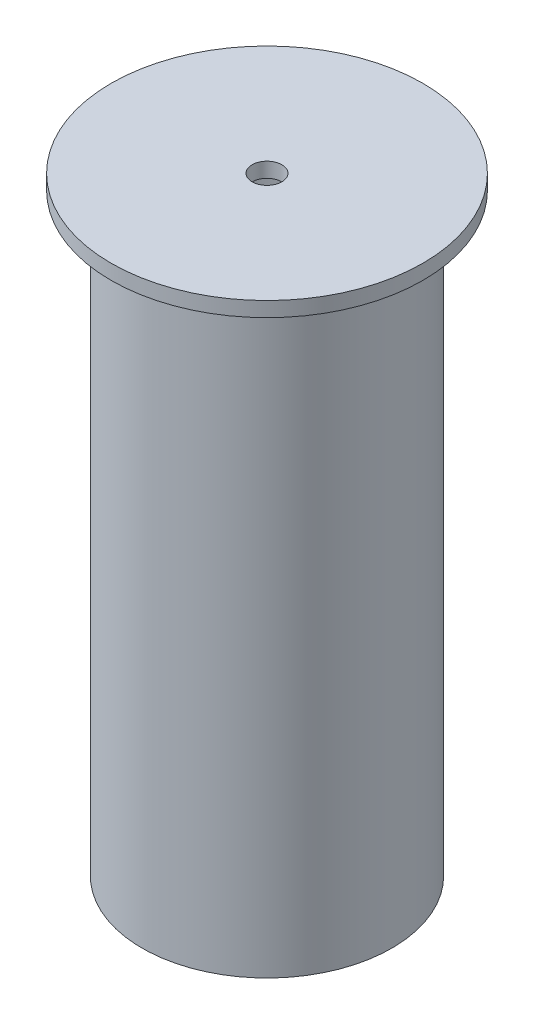
from build123d import *


with BuildPart() as part:
    # Esboço1 → Revolução1 (revolve)
    with BuildSketch(Plane.XY):
        Polygon((10, 410), (105, 410), (105, 400), (84.14, 400), (84.14, 0), (74.74, 0), (74.74, 10), (80.74, 10), (80.74, 400), (10, 400), align=None)
    revolve(axis=Axis((0, 0, 0), (0, 1, 0)))


solid = part.part
